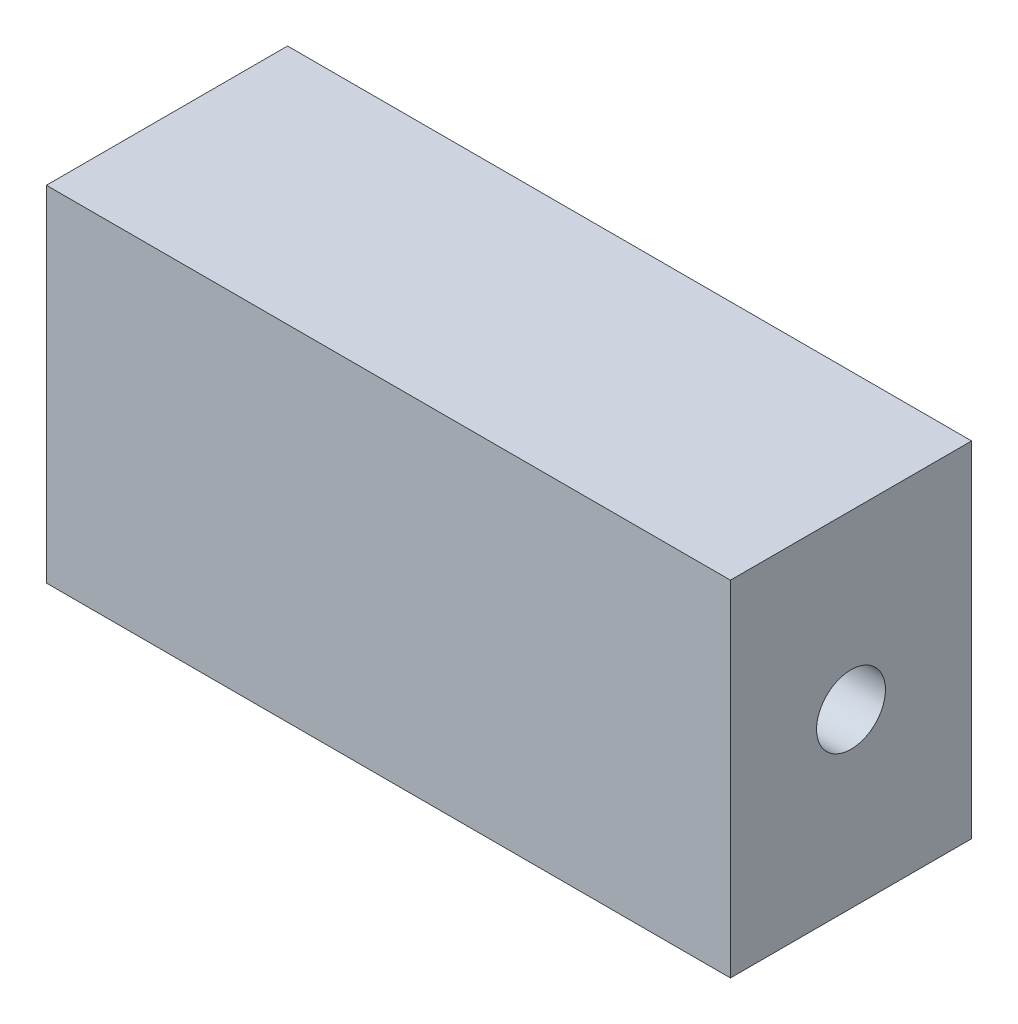
from build123d import *

# Parameters (mm, degrees)
SKETCH1_W           = 99.270032964
SKETCH1_H           = 35
BOSS_EXTRUDE1_DEPTH = 50
SKETCH2_R           = 5
CUT_EXTRUDE1_DEPTH  = 10
SKETCH3_R           = 5
CUT_EXTRUDE2_DEPTH  = 10


with BuildPart() as part:
    # Sketch1 → Boss-Extrude1 (new body)
    with BuildSketch(Plane(origin=(0, 0, 0), x_dir=(1, 0, 0), z_dir=(0, 1, 0))):
        Rectangle(SKETCH1_W, SKETCH1_H)
    extrude(amount=BOSS_EXTRUDE1_DEPTH)

    # Sketch2 → Cut-Extrude1 (cut)
    with BuildSketch(Plane.ZY.offset(49.635016482)):
        with Locations((0, 25)):
            Circle(SKETCH2_R)
    extrude(amount=-CUT_EXTRUDE1_DEPTH, mode=Mode.SUBTRACT)

    # Sketch3 → Cut-Extrude2 (cut)
    with BuildSketch(Plane(origin=(49.635016482, 0, 0), x_dir=(0, 0, -1), z_dir=(1, 0, 0))):
        with Locations((0, 25)):
            Circle(SKETCH3_R)
    extrude(amount=-CUT_EXTRUDE2_DEPTH, mode=Mode.SUBTRACT)


solid = part.part
